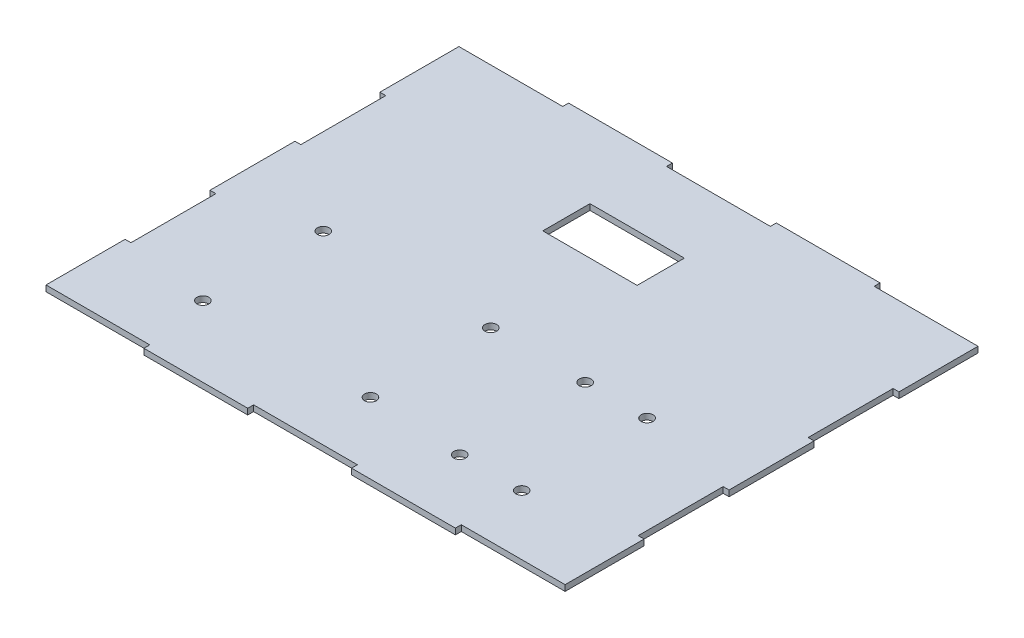
from build123d import *

# Parameters (mm, degrees)
SKETCH1_W           = 279.4
SKETCH1_H           = 228.6
BOSS_EXTRUDE1_DEPTH = 3.175
SKETCH3_R           = 3.175
SKETCH3_W           = 55.88
SKETCH3_H           = 3.175
SKETCH3_W_2         = 3.175
SKETCH3_H_2         = 45.72
SKETCH3_W_3         = 50.8
SKETCH3_H_3         = 25.4
CUT_EXTRUDE1_DEPTH  = 6.35


with BuildPart() as part:
    # Sketch1 → Boss-Extrude1 (new body)
    with BuildSketch(Plane(origin=(0, 0, 0), x_dir=(1, 0, 0), z_dir=(0, 1, 0))):
        Rectangle(SKETCH1_W, SKETCH1_H)
    extrude(amount=BOSS_EXTRUDE1_DEPTH)

    # Sketch3 → Cut-Extrude1 (cut)
    with BuildSketch(Plane(origin=(0, 3.175, 0), x_dir=(1, 0, 0), z_dir=(0, 1, 0))):
        with Locations(Location((0, -11.43, 0), (0, 0, 270))):  # turned: the seam where the file's is
            Circle(SKETCH3_R)
        with Locations(Location((-90.17, -11.43, 0), (0, 0, 270))):  # turned: the seam where the file's is
            Circle(SKETCH3_R)
        with Locations(Location((-90.17, -76.2, 0), (0, 0, 270))):  # turned: the seam where the file's is
            Circle(SKETCH3_R)
        with Locations(Location((0, -76.2, 0), (0, 0, 270))):  # turned: the seam where the file's is
            Circle(SKETCH3_R)
        with Locations(Location((84.130330499, -78.93, 0), (0, 0, 270))):  # turned: the seam where the file's is
            Circle(SKETCH3_R)
        with Locations(Location((84.130330596, -11.43, 0), (0, 0, 270))):  # turned: the seam where the file's is
            Circle(SKETCH3_R)
        with Locations(Location((50.8, -11.43, 0), (0, 0, 270))):  # turned: the seam where the file's is
            Circle(SKETCH3_R)
        with Locations(Location((50.8, -78.93, 0), (0, 0, 270))):  # turned: the seam where the file's is
            Circle(SKETCH3_R)
        with Locations((-111.76, -112.7125)):
            Rectangle(SKETCH3_W, SKETCH3_H)
        with Locations((138.1125, 45.72)):
            Rectangle(SKETCH3_W_2, SKETCH3_H_2)
        with Locations((111.76, -112.7125)):
            Rectangle(SKETCH3_W, SKETCH3_H)
        with Locations((-138.1125, -45.72)):
            Rectangle(SKETCH3_W_2, SKETCH3_H_2)
        with Locations((138.1125, -45.72)):
            Rectangle(SKETCH3_W_2, SKETCH3_H_2)
        with Locations((-138.1125, 45.72)):
            Rectangle(SKETCH3_W_2, SKETCH3_H_2)
        with Locations((0, 112.7125)):
            Rectangle(SKETCH3_W, SKETCH3_H)
        with Locations((0, -112.7125)):
            Rectangle(SKETCH3_W, SKETCH3_H)
        with Locations((111.76, 112.7125)):
            Rectangle(SKETCH3_W, SKETCH3_H)
        with Locations((-111.76, 112.7125)):
            Rectangle(SKETCH3_W, SKETCH3_H)
        with Locations((-5.808092903, 60.467164941)):
            Rectangle(SKETCH3_W_3, SKETCH3_H_3)
    extrude(amount=-CUT_EXTRUDE1_DEPTH, mode=Mode.SUBTRACT)


solid = part.part
